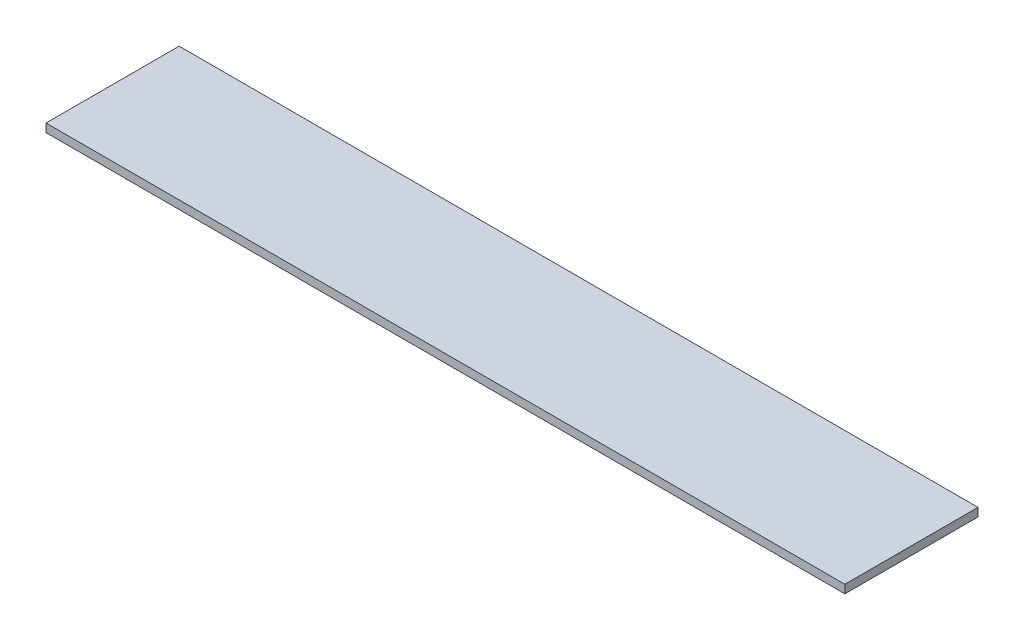
from build123d import *

# Parameters (mm, degrees)
SKETCH2_W           = 152.4
SKETCH2_H           = 25.4
BOSS_EXTRUDE1_DEPTH = 1.5875


with BuildPart() as part:
    # Sketch2 → Boss-Extrude1 (new body)
    with BuildSketch(Plane(origin=(0, 0, 0), x_dir=(1, 0, 0), z_dir=(0, 1, 0))):
        with Locations((76.2, 12.7)):
            Rectangle(SKETCH2_W, SKETCH2_H)
    extrude(amount=BOSS_EXTRUDE1_DEPTH)


solid = part.part
